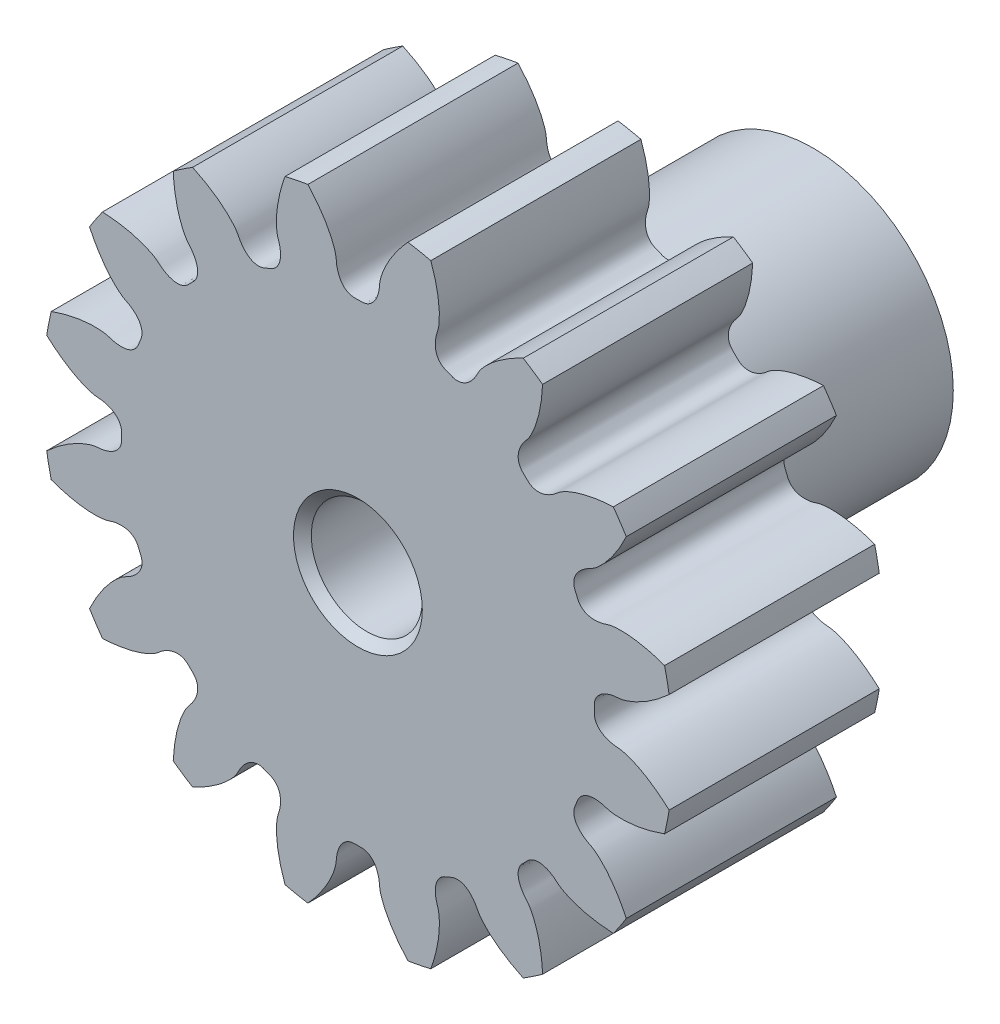
from build123d import *

# Parameters (mm, degrees)
SKETCHREVOLVESPUR01_W       = 6
SKETCHREVOLVESPUR01_H       = 8.999999865
TOOTHEXTRUDECUTSPUR01_DEPTH = 3
PATTERNSPUR01_COUNT         = 16
HUBSKETCHSIDE1_W            = 7
HUBSKETCHSIDE1_H            = 4


with BuildPart() as part:
    # SketchRevolveSpur01 → Spur01 (revolve)
    with BuildSketch(Plane(origin=(0, 0, 0), x_dir=(0, 0, -1), z_dir=(1, 0, 0))):
        with Locations((0, 4.499999933)):
            Rectangle(SKETCHREVOLVESPUR01_W, SKETCHREVOLVESPUR01_H)
    revolve(axis=Axis((0, 0, 0), (0, 0, -1)))

    # SketchToothSpur01 → ToothExtrudeCutSpur01 (cut, symmetric)
    with BuildSketch(Plane.XY):
        with BuildLine():
            ThreePointArc((8.929973087, 1.469039895), (9.049999864, 0), (8.929973087, -1.469039895))
            add(Edge.make_bspline(
                [(8.929973087, -1.469039895), (8.851978125, -1.395869376), (8.734664522, -1.292596236), (8.57583891, -1.166705394), (8.463809949, -1.083860011), (8.356024481, -1.009601886), (8.252924342, -0.943548391), (8.154930322, -0.885296998), (8.062441331, -0.834426523), (7.975833629, -0.790498053), (7.895460095, -0.753056114), (7.821649554, -0.721629414), (7.75470611, -0.695733018), (7.694908646, -0.674866121), (7.642509999, -0.658523582), (7.597737313, -0.646165977), (7.560789153, -0.637310935), (7.465688311, -0.617519472), (7.363004074, -0.618010945), (7.256639379, -0.596738228), (7.207870831, -0.585233491), (7.160835819, -0.571657395), (7.11544051, -0.556068731), (7.071607386, -0.538276029), (7.029252567, -0.518069551), (6.988309269, -0.495137372), (6.948753992, -0.46906144), (6.910655595, -0.439296537), (6.874250948, -0.405172225), (6.840056423, -0.365934545), (6.808983711, -0.320869976), (6.782479785, -0.269536453), (6.762296113, -0.212143084), (6.751921337, -0.155188061), (6.747593415, -0.083968381), (6.751625979, 0), (6.747593415, 0.083968381), (6.751921337, 0.155188061), (6.762296113, 0.212143084), (6.782479785, 0.269536453), (6.808983711, 0.320869976), (6.840056423, 0.365934545), (6.874250948, 0.405172225), (6.910655595, 0.439296537), (6.948753992, 0.46906144), (6.988309269, 0.495137372), (7.029252567, 0.518069551), (7.071607386, 0.538276029), (7.11544051, 0.556068731), (7.160835819, 0.571657395), (7.207870831, 0.585233491), (7.256639379, 0.596738228), (7.363004074, 0.618010945), (7.465688311, 0.617519472), (7.560789153, 0.637310935), (7.597737313, 0.646165977), (7.642509999, 0.658523582), (7.694908646, 0.674866121), (7.75470611, 0.695733018), (7.821649554, 0.721629414), (7.895460095, 0.753056114), (7.975833629, 0.790498053), (8.062441331, 0.834426523), (8.154930322, 0.885296998), (8.252924342, 0.943548391), (8.356024481, 1.009601886), (8.463809949, 1.083860011), (8.57583891, 1.166705394), (8.734664522, 1.292596236), (8.851978125, 1.395869376), (8.929973087, 1.469039895)],
                knots=[0, 0, 0, 0, 0.057364688, 0.083782636, 0.108690988, 0.132089742, 0.1539789, 0.17435846, 0.193228424, 0.21058879, 0.22643956, 0.240780732, 0.253612308, 0.264934286, 0.274746668, 0.283049453, 0.289842641, 0.295126232, 0.335124058, 0.344314279, 0.353261984, 0.361998456, 0.370561496, 0.378996872, 0.38735999, 0.39571764, 0.404149506, 0.41274873, 0.42162022, 0.430874507, 0.440614268, 0.450911202, 0.461775012, 0.473124879, 0.481840265, 0.5, 0.518159735, 0.526875121, 0.538224988, 0.549088798, 0.559385732, 0.569125493, 0.57837978, 0.58725127, 0.595850494, 0.60428236, 0.61264001, 0.621003128, 0.629438504, 0.638001544, 0.646738016, 0.655685721, 0.664875942, 0.704873768, 0.710157359, 0.716950547, 0.725253332, 0.735065714, 0.746387692, 0.759219268, 0.77356044, 0.78941121, 0.806771576, 0.82564154, 0.8460211, 0.867910258, 0.891309012, 0.916217364, 0.942635312, 1, 1, 1, 1], degree=3))
        make_face()
    toothextrudecutspur01 = extrude(amount=TOOTHEXTRUDECUTSPUR01_DEPTH, both=True, mode=Mode.SUBTRACT)

    # PatternSpur01: ToothExtrudeCutSpur01 ×16 about axis
    patternspur01_axis = Axis((0, 0, 50), (0, 0, -1))
    for i in range(1, PATTERNSPUR01_COUNT):
        add(toothextrudecutspur01.rotate(patternspur01_axis, i * 360 / PATTERNSPUR01_COUNT), mode=Mode.SUBTRACT)

    # HubSketchSide1 → HubRevolve1 (revolve)
    with BuildSketch(Plane(origin=(0, 0, 0), x_dir=(0, 0, -1), z_dir=(1, 0, 0))):
        with Locations((6.5, 2)):
            Rectangle(HUBSKETCHSIDE1_W, HUBSKETCHSIDE1_H)
    revolve(axis=Axis((0, 0, 0), (0, 0, -1)))

    # BoreRevolveSketch → BoreRevolveCut (revolve, cut)
    with BuildSketch(Plane(origin=(0, 0, 0), x_dir=(0, 0, -1), z_dir=(1, 0, 0))):
        Polygon((-3, 0), (10, 0), (10, 1.838999996), (9.746000004, 1.585), (-2.746000004, 1.585), (-3, 1.838999996), align=None)
    revolve(axis=Axis((0, 0, 0), (0, 0, -1)), mode=Mode.SUBTRACT)


solid = part.part
